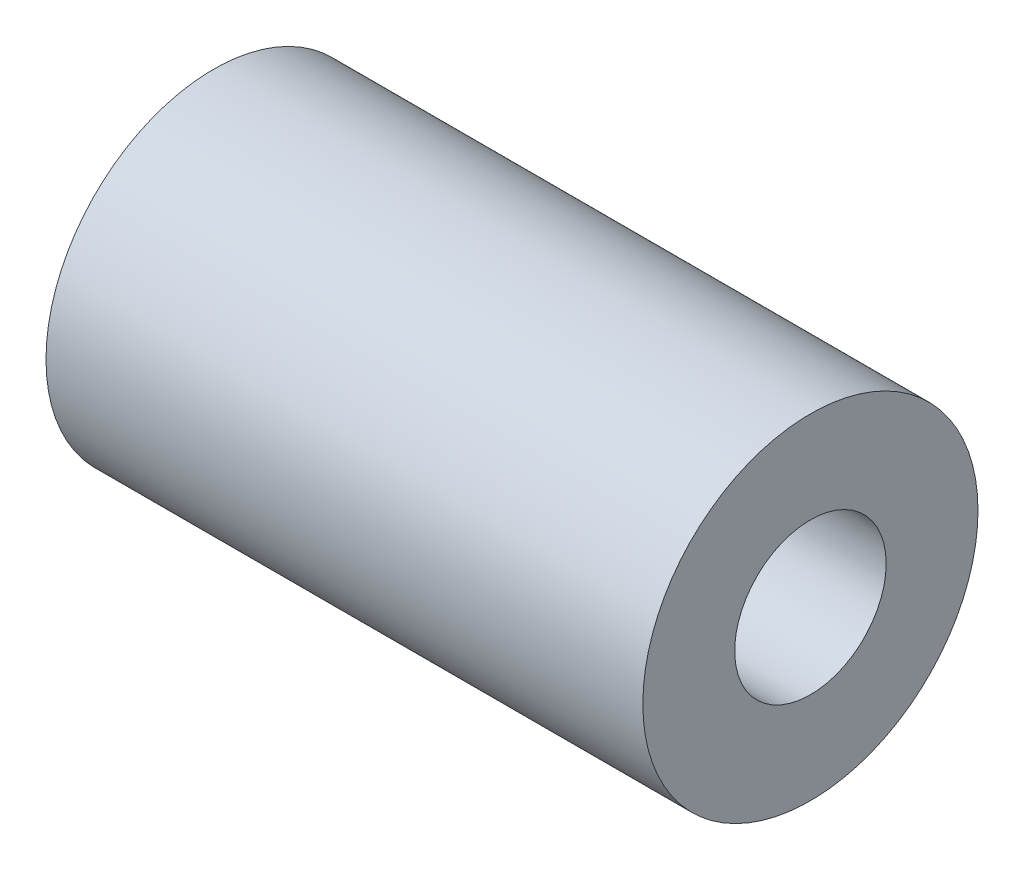
from build123d import *

# Parameters (mm, degrees)
SKETCH_1_R      = 3.65
SKETCH_1_R_2    = 1.65
EXTRUDE_1_DEPTH = 13


with BuildPart() as part:
    # 草图1 → 凸台-拉伸1 (new body)
    with BuildSketch(Plane(origin=(0, 0, 0), x_dir=(0, 0, -1), z_dir=(1, 0, 0))):
        Circle(SKETCH_1_R)
        Circle(SKETCH_1_R_2, mode=Mode.SUBTRACT)
    extrude(amount=EXTRUDE_1_DEPTH)


solid = part.part
